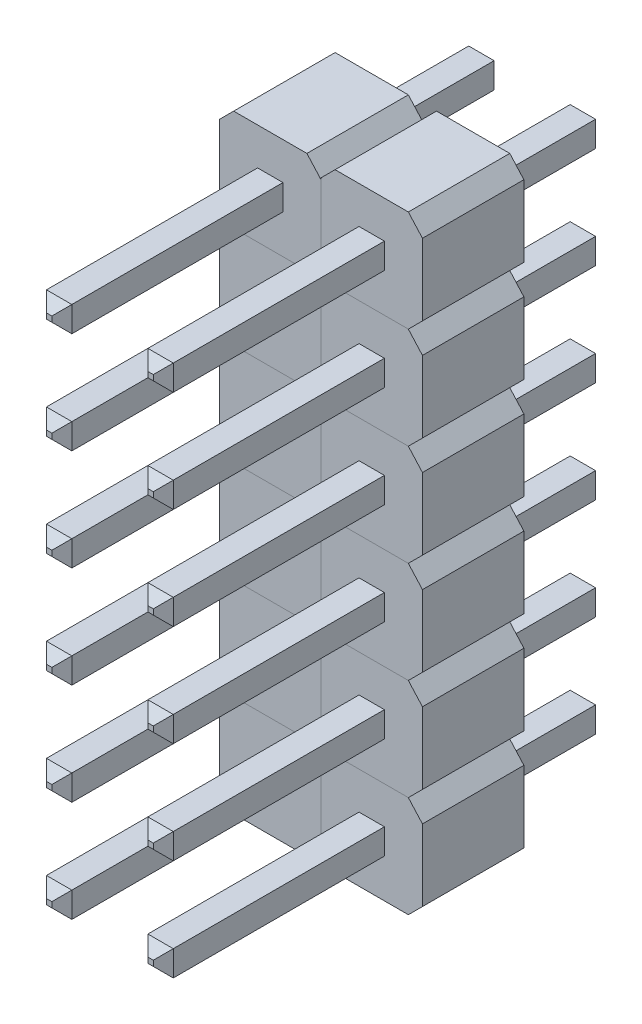
from build123d import *

# Parameters (mm, degrees)
PIN_DRAWING_W            = 0.636
PIN_DRAWING_H            = 0.636
BOSS_EXTRUDE1_DEPTH      = 2.54
SKETCH1_W                = 0.636
SKETCH1_H                = 0.636
BOSS_EXTRUDE2_DEPTH      = 5.5372
BOSS_EXTRUDE2_DEPTH_BACK = 5.5372
CHAMFER1_SIZE            = 0.25
LPATTERN2_COUNT          = 6
LPATTERN2_PITCH          = 2.54
LPATTERN2_2_COUNT        = 2
LPATTERN2_2_PITCH        = 2.54


with BuildPart() as part:
    # pin_drawing → Boss-Extrude1 (new body)
    with BuildSketch(Plane.XY):
        Polygon((-0.916946609, 1.25), (0.916946609, 1.25), (1.2705, 0.856446609), (1.2705, -0.936446609), (0.916946609, -1.29), (-0.916946609, -1.29), (-1.2705, -0.896446609), (-1.2705, 0.896446609), align=None)
        Rectangle(PIN_DRAWING_W, PIN_DRAWING_H, mode=Mode.SUBTRACT)
    extrude(amount=BOSS_EXTRUDE1_DEPTH)


with BuildPart() as body_2:
    # Sketch1 → Boss-Extrude2 (new body, two sides)
    with BuildSketch(Plane.XY.offset(2.54)) as boss_extrude2_sk:
        Rectangle(SKETCH1_W, SKETCH1_H)
    extrude(amount=BOSS_EXTRUDE2_DEPTH)
    extrude(boss_extrude2_sk.sketch, amount=-BOSS_EXTRUDE2_DEPTH_BACK)

    # Chamfer1
    chamfer1_edges = [body_2.edges().sort_by_distance(p)[0] for p in [
        (0, 0.318, -2.9972),
        (0, -0.318, 8.0772),
        (0.318, 0, 8.0772),
        (-0.318, 0, -2.9972),
        (0, 0.318, 8.0772),
        (-0.318, 0, 8.0772),
        (0, -0.318, -2.9972),
        (0.318, 0, -2.9972),
    ]]
    chamfer(chamfer1_edges, length=CHAMFER1_SIZE)


with BuildPart() as lpattern2_1:
    # LPattern2: pattern copy
    add(body_2.part.moved(Location(Vector(0, -1, 0) * (1 * LPATTERN2_PITCH))))


with BuildPart() as lpattern2_2:
    # LPattern2: pattern copy
    add(body_2.part.moved(Location(Vector(0, -1, 0) * (2 * LPATTERN2_PITCH))))


with BuildPart() as lpattern2_3:
    # LPattern2: pattern copy
    add(body_2.part.moved(Location(Vector(0, -1, 0) * (3 * LPATTERN2_PITCH))))


with BuildPart() as lpattern2_4:
    # LPattern2: pattern copy
    add(body_2.part.moved(Location(Vector(0, -1, 0) * (4 * LPATTERN2_PITCH))))


with BuildPart() as lpattern2_5:
    # LPattern2: pattern copy
    add(body_2.part.moved(Location(Vector(0, -1, 0) * (5 * LPATTERN2_PITCH))))


with BuildPart() as lpattern2_6:
    # LPattern2: pattern copy
    add(part.part.moved(Location(Vector(0, -1, 0) * (1 * LPATTERN2_PITCH))))


with BuildPart() as lpattern2_7:
    # LPattern2: pattern copy
    add(part.part.moved(Location(Vector(0, -1, 0) * (2 * LPATTERN2_PITCH))))


with BuildPart() as lpattern2_8:
    # LPattern2: pattern copy
    add(part.part.moved(Location(Vector(0, -1, 0) * (3 * LPATTERN2_PITCH))))


with BuildPart() as lpattern2_9:
    # LPattern2: pattern copy
    add(part.part.moved(Location(Vector(0, -1, 0) * (4 * LPATTERN2_PITCH))))


with BuildPart() as lpattern2_10:
    # LPattern2: pattern copy
    add(part.part.moved(Location(Vector(0, -1, 0) * (5 * LPATTERN2_PITCH))))


with BuildPart() as lpattern2_2_1:
    # LPattern2 2: pattern copy
    add(body_2.part.moved(Location(Vector(1, 0, 0) * (1 * LPATTERN2_2_PITCH))))


with BuildPart() as lpattern2_2_2:
    # LPattern2 2: pattern copy
    add(part.part.moved(Location(Vector(1, 0, 0) * (1 * LPATTERN2_2_PITCH))))


with BuildPart() as lpattern2_2_3:
    # LPattern2 2: pattern copy
    add(lpattern2_1.part.moved(Location(Vector(1, 0, 0) * (1 * LPATTERN2_2_PITCH))))


with BuildPart() as lpattern2_2_4:
    # LPattern2 2: pattern copy
    add(lpattern2_2.part.moved(Location(Vector(1, 0, 0) * (1 * LPATTERN2_2_PITCH))))


with BuildPart() as lpattern2_2_5:
    # LPattern2 2: pattern copy
    add(lpattern2_3.part.moved(Location(Vector(1, 0, 0) * (1 * LPATTERN2_2_PITCH))))


with BuildPart() as lpattern2_2_6:
    # LPattern2 2: pattern copy
    add(lpattern2_4.part.moved(Location(Vector(1, 0, 0) * (1 * LPATTERN2_2_PITCH))))


with BuildPart() as lpattern2_2_7:
    # LPattern2 2: pattern copy
    add(lpattern2_5.part.moved(Location(Vector(1, 0, 0) * (1 * LPATTERN2_2_PITCH))))


with BuildPart() as lpattern2_2_8:
    # LPattern2 2: pattern copy
    add(lpattern2_6.part.moved(Location(Vector(1, 0, 0) * (1 * LPATTERN2_2_PITCH))))


with BuildPart() as lpattern2_2_9:
    # LPattern2 2: pattern copy
    add(lpattern2_7.part.moved(Location(Vector(1, 0, 0) * (1 * LPATTERN2_2_PITCH))))


with BuildPart() as lpattern2_2_10:
    # LPattern2 2: pattern copy
    add(lpattern2_8.part.moved(Location(Vector(1, 0, 0) * (1 * LPATTERN2_2_PITCH))))


with BuildPart() as lpattern2_2_11:
    # LPattern2 2: pattern copy
    add(lpattern2_9.part.moved(Location(Vector(1, 0, 0) * (1 * LPATTERN2_2_PITCH))))


with BuildPart() as lpattern2_2_12:
    # LPattern2 2: pattern copy
    add(lpattern2_10.part.moved(Location(Vector(1, 0, 0) * (1 * LPATTERN2_2_PITCH))))


solid = Compound([part.part, body_2.part, lpattern2_1.part, lpattern2_2.part, lpattern2_3.part, lpattern2_4.part, lpattern2_5.part, lpattern2_6.part, lpattern2_7.part, lpattern2_8.part, lpattern2_9.part, lpattern2_10.part, lpattern2_2_1.part, lpattern2_2_2.part, lpattern2_2_3.part, lpattern2_2_4.part, lpattern2_2_5.part, lpattern2_2_6.part, lpattern2_2_7.part, lpattern2_2_8.part, lpattern2_2_9.part, lpattern2_2_10.part, lpattern2_2_11.part, lpattern2_2_12.part])
